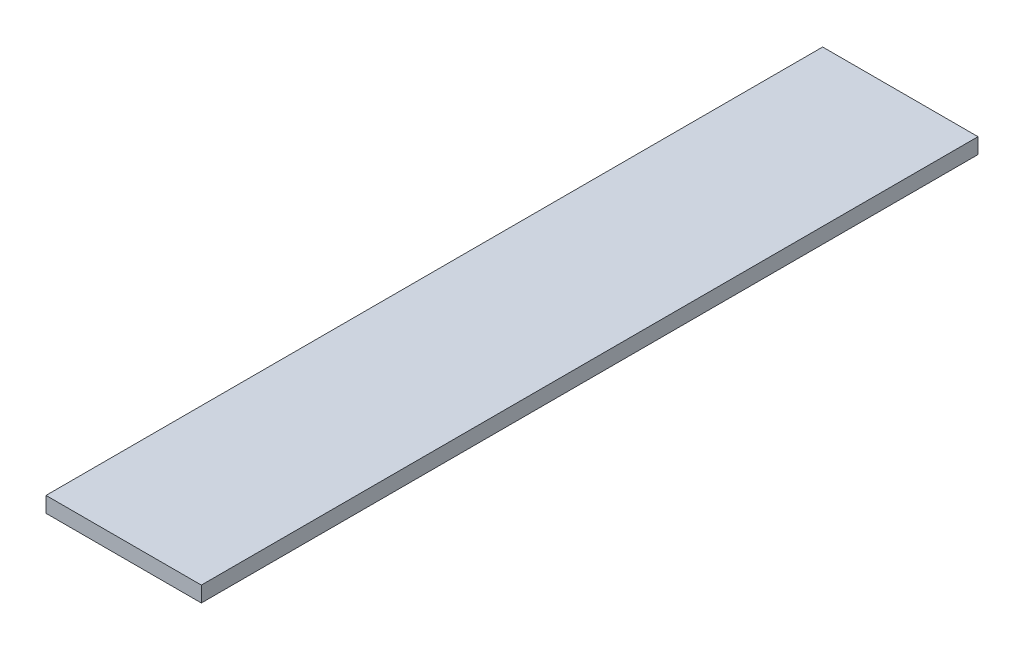
from build123d import *

# Parameters (mm, degrees)
SKETCH1_W           = 20000
SKETCH1_H           = 2000
BOSS_EXTRUDE1_DEPTH = 100000


with BuildPart() as part:
    # Sketch1 → Boss-Extrude1 (new body)
    with BuildSketch(Plane.XY):
        with Locations((10000, -1000)):
            Rectangle(SKETCH1_W, SKETCH1_H)
    extrude(amount=BOSS_EXTRUDE1_DEPTH)


solid = part.part
